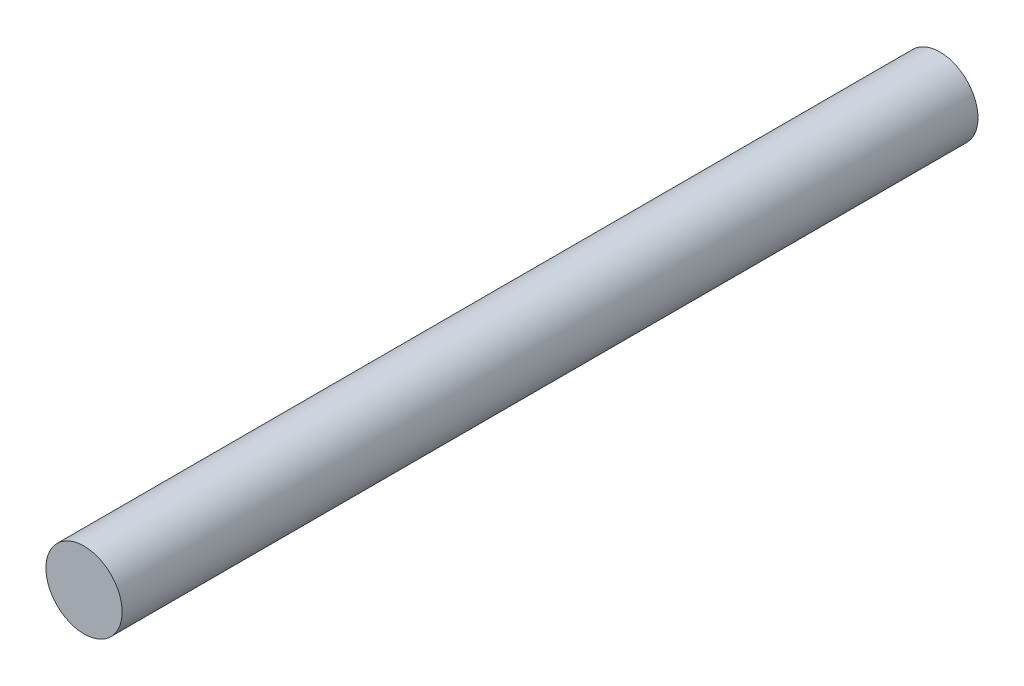
from build123d import *

# Parameters (mm, degrees)
SKETCH1_R           = 4.7625
BOSS_EXTRUDE1_DEPTH = 107


with BuildPart() as part:
    # Sketch1 → Boss-Extrude1 (new body)
    with BuildSketch(Plane.XY):
        Circle(SKETCH1_R)
    extrude(amount=BOSS_EXTRUDE1_DEPTH)


solid = part.part
